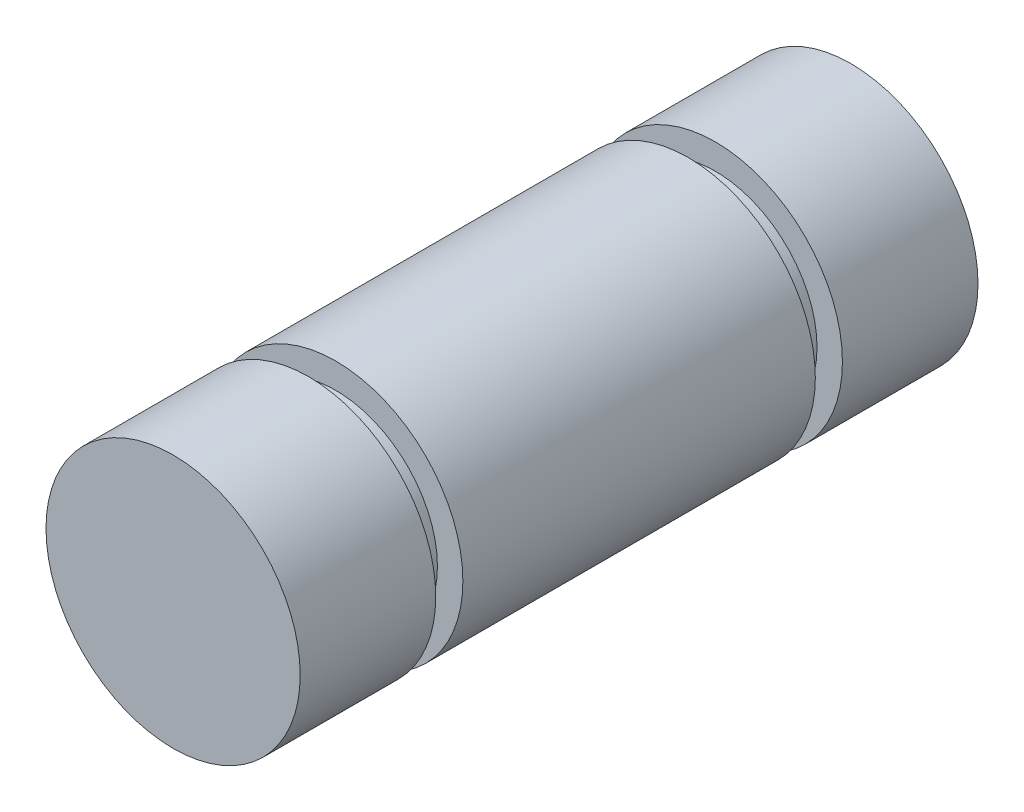
from build123d import *

# Parameters (mm, degrees)
SKETCH1_R           = 4.7625
BOSS_EXTRUDE1_DEPTH = 12.7
SKETCH2_W           = 0.9525
SKETCH2_H           = 1.016


with BuildPart() as part:
    # Sketch1 → Boss-Extrude1 (new body, symmetric)
    with BuildSketch(Plane.XY):
        Circle(SKETCH1_R)
    extrude(amount=BOSS_EXTRUDE1_DEPTH, both=True)

    # Sketch2 → Cut-Revolve1 (revolve, cut)
    with BuildSketch(Plane(origin=(0, 0, 0), x_dir=(1, 0, 0), z_dir=(0, 1, 0))):
        with Locations((4.28625, 7.112)):
            Rectangle(SKETCH2_W, SKETCH2_H)
        with Locations((4.28625, -7.112)):
            Rectangle(SKETCH2_W, SKETCH2_H)
    revolve(axis=Axis((0, 0, 12.7), (0, 0, -1)), mode=Mode.SUBTRACT)


solid = part.part
